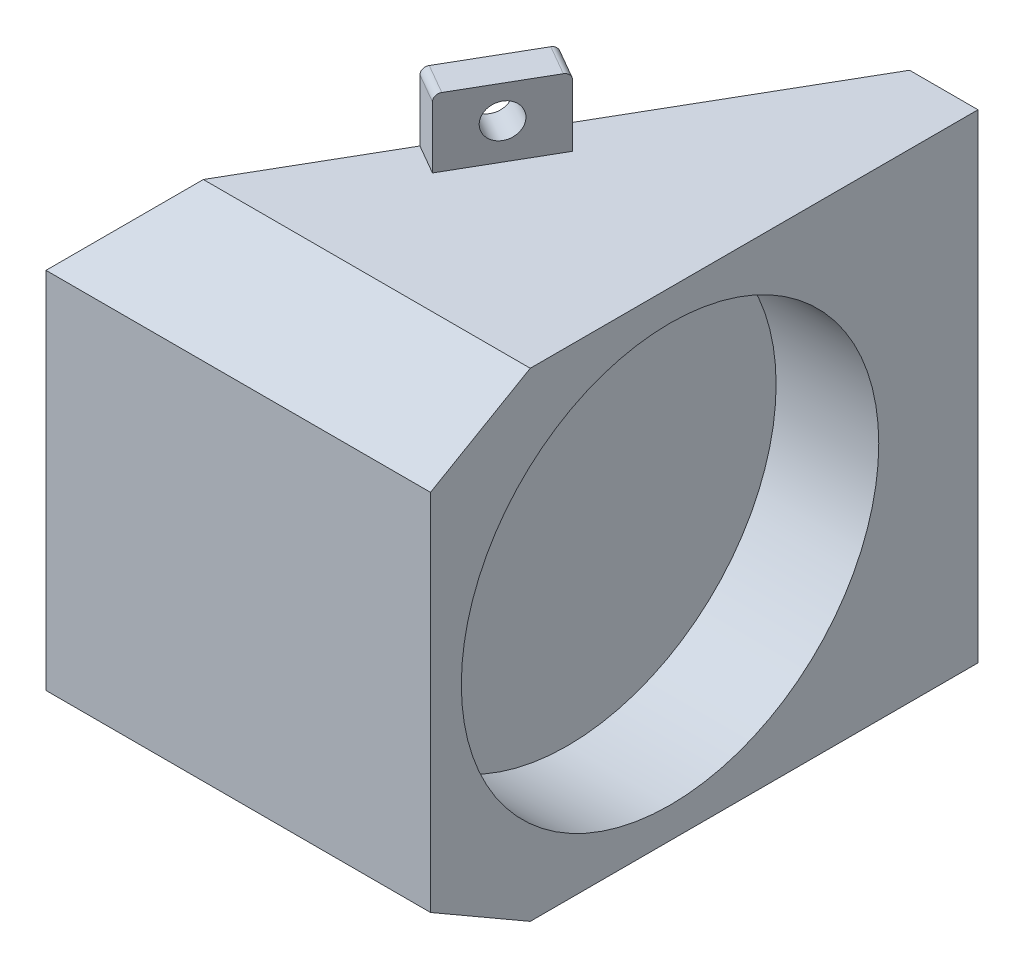
from build123d import *

# Parameters (mm, degrees)
BOSS_EXTRUDE1_DEPTH = 88.9
SKETCH2_R           = 38.735
CUT_EXTRUDE1_DEPTH  = 6.35
SKETCH3_W           = 101.6
SKETCH3_H           = 88.9
SKETCH3_R           = 38.735
BOSS_EXTRUDE2_DEPTH = 12.7
BOSS_EXTRUDE4_DEPTH = 12.7
SKETCH6_R           = 3.175
CUT_EXTRUDE2_DEPTH  = 58.15
BOSS_EXTRUDE5_DEPTH = 12.7
SKETCH8_R           = 3.175
CUT_EXTRUDE3_DEPTH  = 58.15
FILLET1_R           = 1.27
CUT_EXTRUDE4_DEPTH  = 72.35878735


with BuildPart() as part:
    # Sketch1 → Boss-Extrude1 (new body)
    with BuildSketch(Plane(origin=(0, 0, 0), x_dir=(1, 0, 0), z_dir=(0, 1, 0))):
        Polygon((0, 0), (0, 101.6), (-58.65878735, 0), align=None)
    extrude(amount=BOSS_EXTRUDE1_DEPTH)

    # Sketch2 → Cut-Extrude1 (cut)
    with BuildSketch(Plane(origin=(0, 0, 0), x_dir=(0, 0, -1), z_dir=(1, 0, 0))):
        with Locations((44.45, 44.45)):
            Circle(SKETCH2_R)
    extrude(amount=-CUT_EXTRUDE1_DEPTH, mode=Mode.SUBTRACT)

    # Sketch3 → Boss-Extrude2 (add)
    with BuildSketch(Plane(origin=(0, 0, 0), x_dir=(0, 0, -1), z_dir=(1, 0, 0))):
        with Locations((50.8, 44.45)):
            Rectangle(SKETCH3_W, SKETCH3_H)
        with Locations((44.45, 44.45)):
            Circle(SKETCH3_R, mode=Mode.SUBTRACT)
    extrude(amount=BOSS_EXTRUDE2_DEPTH)

    # Sketch5 → Boss-Extrude4 (add)
    with BuildSketch(Plane.XZ):
        Polygon((-23.197585425, -61.42060343), (-32.722585425, -44.922819488), (-27.223324111, -41.747819488), (-17.698324111, -58.24560343), align=None)
    extrude(amount=BOSS_EXTRUDE4_DEPTH)

    # Sketch6 → Cut-Extrude2 (cut, through all)
    with BuildSketch(Plane(origin=(-38.494829198, 0, -22.225), x_dir=(0.5, 0, -0.866025404), z_dir=(0.866025404, 0, 0.5))):
        with Locations((32.068010174, -6.46367916)):
            Circle(SKETCH6_R)
    extrude(amount=-CUT_EXTRUDE2_DEPTH, mode=Mode.SUBTRACT)

    # Sketch7 → Boss-Extrude5 (add)
    with BuildSketch(Plane(origin=(0, 88.9, 0), x_dir=(1, 0, 0), z_dir=(0, 1, 0))):
        Polygon((-23.73378735, 60.491874454), (-18.234526036, 57.316874454), (-27.759526036, 40.819090512), (-33.25878735, 43.994090512), align=None)
    extrude(amount=BOSS_EXTRUDE5_DEPTH)

    # Sketch8 → Cut-Extrude3 (cut, through all)
    with BuildSketch(Plane(origin=(-38.494829198, 0, -22.225), x_dir=(0.5, 0, -0.866025404), z_dir=(0.866025404, 0, 0.5))):
        with Locations((30.995606325, 95.541359592)):
            Circle(SKETCH8_R)
    extrude(amount=-CUT_EXTRUDE3_DEPTH, mode=Mode.SUBTRACT)

    # Fillet1
    fillet1_edges = [part.edges().sort_by_distance(p)[0] for p in [
        (-20.447954768, -12.7, -59.83310343),
        (-29.972954768, -12.7, -43.335319488),
        (-30.509156693, 101.6, -42.406590512),
        (-20.984156693, 101.6, -58.904374454),
    ]]
    fillet(fillet1_edges, radius=FILLET1_R)

    # Sketch9 → Cut-Extrude4 (cut, through all)
    with BuildSketch(Plane(origin=(12.7, 0, 0), x_dir=(0, 0, -1), z_dir=(1, 0, 0))):
        Polygon((18.509160794, 88.9), (0, 78.213731033), (0, 88.9), align=None)
        Polygon((0, 10.686268967), (0, 0), (18.509160794, 0), align=None)
    extrude(amount=-CUT_EXTRUDE4_DEPTH, mode=Mode.SUBTRACT)


solid = part.part
